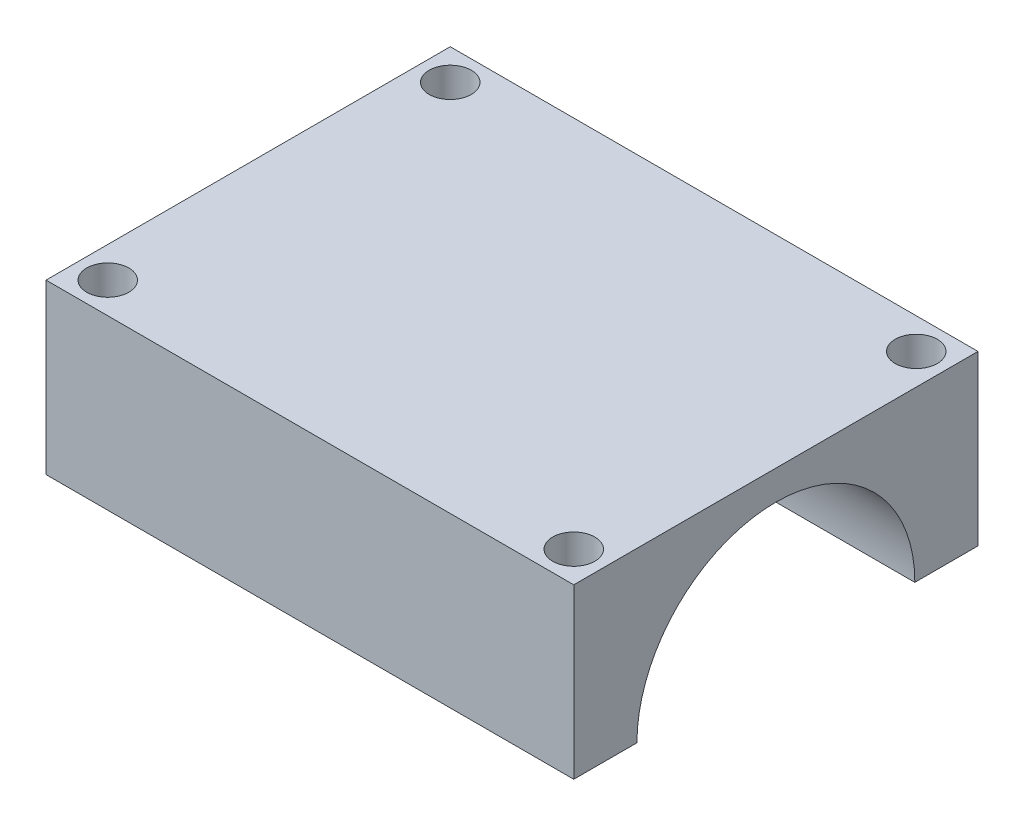
from build123d import *

# Parameters (mm, degrees)
SKETCH1_W           = 47
SKETCH1_H           = 36
BOSS_EXTRUDE1_DEPTH = 30
SKETCH3_R           = 12.375
CUT_EXTRUDE1_DEPTH  = 47
SKETCH5_R           = 1.875
CUT_EXTRUDE2_DEPTH  = 40
CUT_EXTRUDE3_START  = 23.5
SKETCH7_W           = 36
SKETCH7_H           = 15
CUT_EXTRUDE3_DEPTH  = 48


with BuildPart() as part:
    # Sketch1 → Boss-Extrude1 (new body)
    with BuildSketch(Plane(origin=(0, 0, 0), x_dir=(1, 0, 0), z_dir=(0, 1, 0))):
        Rectangle(SKETCH1_W, SKETCH1_H)
    extrude(amount=BOSS_EXTRUDE1_DEPTH)

    # Sketch3 → Cut-Extrude1 (cut)
    with BuildSketch(Plane(origin=(23.5, 0, 0), x_dir=(0, 0, -1), z_dir=(1, 0, 0))):
        with Locations((0, 15)):
            Circle(SKETCH3_R)
    extrude(amount=-CUT_EXTRUDE1_DEPTH, mode=Mode.SUBTRACT)

    # Sketch5 → Cut-Extrude2 (cut)
    with BuildSketch(Plane(origin=(0, 30, 0), x_dir=(1, 0, 0), z_dir=(0, 1, 0))):
        with Locations((-20.75, 15.25)):
            Circle(SKETCH5_R)
        with Locations((-20.75, -15.25)):
            Circle(SKETCH5_R)
        with Locations((20.75, -15.25)):
            Circle(SKETCH5_R)
        with Locations((20.75, 15.25)):
            Circle(SKETCH5_R)
    extrude(amount=-CUT_EXTRUDE2_DEPTH, mode=Mode.SUBTRACT)

    # Sketch7 → Cut-Extrude3 (cut, through all)
    with BuildSketch(Plane(origin=(0, 0, 0), x_dir=(0, 0, -1), z_dir=(1, 0, 0)).offset(CUT_EXTRUDE3_START)):
        with Locations((0, 7.5)):
            Rectangle(SKETCH7_W, SKETCH7_H)
    extrude(amount=-CUT_EXTRUDE3_DEPTH, mode=Mode.SUBTRACT)


solid = part.part
